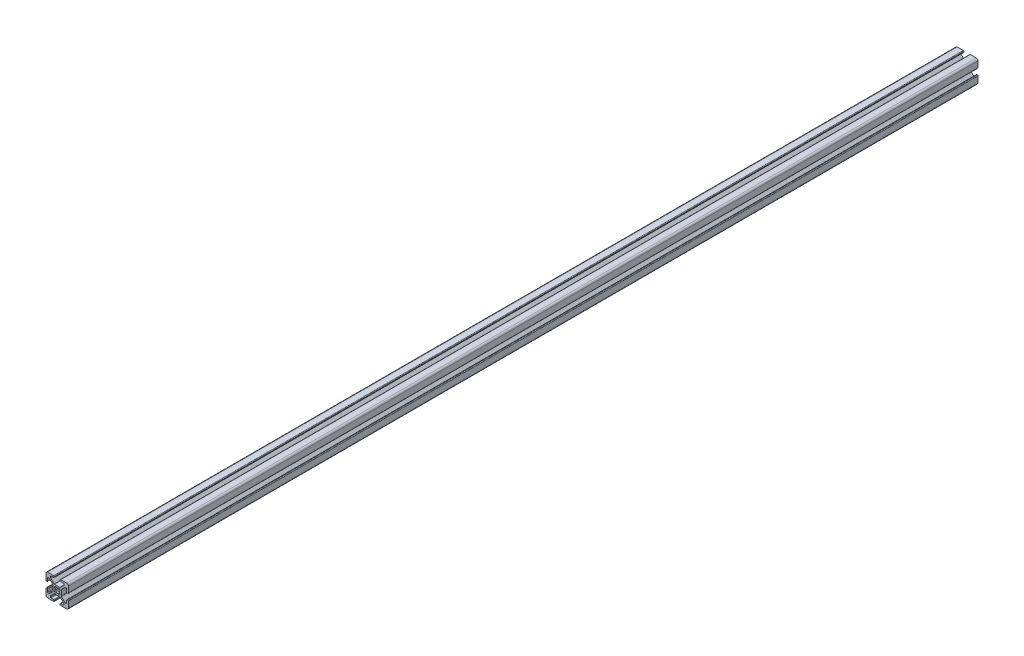
from build123d import *

# Parameters (mm, degrees)
EXTRUDE1_DEPTH = 406.4


with BuildPart() as part:
    # Sketch1 → Extrude1 (new body, symmetric)
    with BuildSketch(Plane.XY):
        with BuildLine():
            Line((9.492, 2.63), (9.008, 2.63))
            ThreePointArc((9.008, 2.63), (8.648789755, 2.778789755), (8.5, 3.138))
            Line((8.5, 3.138), (8.5, 5.487))
            ThreePointArc((8.5, 5.487), (8.351210245, 5.846210245), (7.992, 5.995))
            Line((7.992, 5.995), (7.266080661, 5.995))
            ThreePointArc((7.266080661, 5.995), (7.071677478, 5.956330803), (6.906870417, 5.846210245))
            Line((6.906870417, 5.846210245), (3.803789755, 2.743129583))
            ThreePointArc((3.803789755, 2.743129583), (3.693669197, 2.578322522), (3.655, 2.383919339))
            Line((3.655, 2.383919339), (3.655, -2.383919339))
            ThreePointArc((3.655, -2.383919339), (3.693669197, -2.578322522), (3.803789755, -2.743129583))
            Line((3.803789755, -2.743129583), (6.906870417, -5.846210245))
            ThreePointArc((6.906870417, -5.846210245), (7.071677478, -5.956330803), (7.266080661, -5.995))
            Line((7.266080661, -5.995), (7.992, -5.995))
            ThreePointArc((7.992, -5.995), (8.351210245, -5.846210245), (8.5, -5.487))
            Line((8.5, -5.487), (8.5, -3.138))
            ThreePointArc((8.5, -3.138), (8.648789755, -2.778789755), (9.008, -2.63))
            Line((9.008, -2.63), (9.492, -2.63))
            ThreePointArc((9.492, -2.63), (9.851210245, -2.778789755), (10, -3.138))
            Line((10, -3.138), (10, -8.5))
            ThreePointArc((10, -8.5), (9.560660172, -9.560660172), (8.5, -10))
            Line((8.5, -10), (3.138, -10))
            ThreePointArc((3.138, -10), (2.778789755, -9.851210245), (2.63, -9.492))
            Line((2.63, -9.492), (2.63, -9.008))
            ThreePointArc((2.63, -9.008), (2.778789755, -8.648789755), (3.138, -8.5))
            Line((3.138, -8.5), (5.487, -8.5))
            ThreePointArc((5.487, -8.5), (5.846210245, -8.351210245), (5.995, -7.992))
            Line((5.995, -7.992), (5.995, -7.266080661))
            ThreePointArc((5.995, -7.266080661), (5.956330803, -7.071677478), (5.846210245, -6.906870417))
            Line((5.846210245, -6.906870417), (2.743129583, -3.803789755))
            ThreePointArc((2.743129583, -3.803789755), (2.578322522, -3.693669197), (2.383919339, -3.655))
            Line((2.383919339, -3.655), (-2.383919339, -3.655))
            ThreePointArc((-2.383919339, -3.655), (-2.578322522, -3.693669197), (-2.743129583, -3.803789755))
            Line((-2.743129583, -3.803789755), (-5.846210245, -6.906870417))
            ThreePointArc((-5.846210245, -6.906870417), (-5.956330803, -7.071677478), (-5.995, -7.266080661))
            Line((-5.995, -7.266080661), (-5.995, -7.992))
            ThreePointArc((-5.995, -7.992), (-5.846210245, -8.351210245), (-5.487, -8.5))
            Line((-5.487, -8.5), (-3.138, -8.5))
            ThreePointArc((-3.138, -8.5), (-2.778789755, -8.648789755), (-2.63, -9.008))
            Line((-2.63, -9.008), (-2.63, -9.492))
            ThreePointArc((-2.63, -9.492), (-2.778789755, -9.851210245), (-3.138, -10))
            Line((-3.138, -10), (-8.5, -10))
            ThreePointArc((-8.5, -10), (-9.560660172, -9.560660172), (-10, -8.5))
            Line((-10, -8.5), (-10, -3.138))
            ThreePointArc((-10, -3.138), (-9.851210245, -2.778789755), (-9.492, -2.63))
            Line((-9.492, -2.63), (-9.008, -2.63))
            ThreePointArc((-9.008, -2.63), (-8.648789755, -2.778789755), (-8.5, -3.138))
            Line((-8.5, -3.138), (-8.5, -5.487))
            ThreePointArc((-8.5, -5.487), (-8.351210245, -5.846210245), (-7.992, -5.995))
            Line((-7.992, -5.995), (-7.266080661, -5.995))
            ThreePointArc((-7.266080661, -5.995), (-7.071677478, -5.956330803), (-6.906870417, -5.846210245))
            Line((-6.906870417, -5.846210245), (-3.803789755, -2.743129583))
            ThreePointArc((-3.803789755, -2.743129583), (-3.693669197, -2.578322522), (-3.655, -2.383919339))
            Line((-3.655, -2.383919339), (-3.655, 2.383919339))
            ThreePointArc((-3.655, 2.383919339), (-3.693669197, 2.578322522), (-3.803789755, 2.743129583))
            Line((-3.803789755, 2.743129583), (-6.906870417, 5.846210245))
            ThreePointArc((-6.906870417, 5.846210245), (-7.071677478, 5.956330803), (-7.266080661, 5.995))
            Line((-7.266080661, 5.995), (-7.992, 5.995))
            ThreePointArc((-7.992, 5.995), (-8.351210245, 5.846210245), (-8.5, 5.487))
            Line((-8.5, 5.487), (-8.5, 3.138))
            ThreePointArc((-8.5, 3.138), (-8.648789755, 2.778789755), (-9.008, 2.63))
            Line((-9.008, 2.63), (-9.492, 2.63))
            ThreePointArc((-9.492, 2.63), (-9.851210245, 2.778789755), (-10, 3.138))
            Line((-10, 3.138), (-10, 8.5))
            ThreePointArc((-10, 8.5), (-9.560660172, 9.560660172), (-8.5, 10))
            Line((-8.5, 10), (-3.138, 10))
            ThreePointArc((-3.138, 10), (-2.778789755, 9.851210245), (-2.63, 9.492))
            Line((-2.63, 9.492), (-2.63, 9.008))
            ThreePointArc((-2.63, 9.008), (-2.778789755, 8.648789755), (-3.138, 8.5))
            Line((-3.138, 8.5), (-5.487, 8.5))
            ThreePointArc((-5.487, 8.5), (-5.846210245, 8.351210245), (-5.995, 7.992))
            Line((-5.995, 7.992), (-5.995, 7.266080661))
            ThreePointArc((-5.995, 7.266080661), (-5.956330803, 7.071677478), (-5.846210245, 6.906870417))
            Line((-5.846210245, 6.906870417), (-2.743129583, 3.803789755))
            ThreePointArc((-2.743129583, 3.803789755), (-2.578322522, 3.693669197), (-2.383919339, 3.655))
            Line((-2.383919339, 3.655), (2.383919339, 3.655))
            ThreePointArc((2.383919339, 3.655), (2.578322522, 3.693669197), (2.743129583, 3.803789755))
            Line((2.743129583, 3.803789755), (5.846210245, 6.906870417))
            ThreePointArc((5.846210245, 6.906870417), (5.956330803, 7.071677478), (5.995, 7.266080661))
            Line((5.995, 7.266080661), (5.995, 7.992))
            ThreePointArc((5.995, 7.992), (5.846210245, 8.351210245), (5.487, 8.5))
            Line((5.487, 8.5), (3.138, 8.5))
            ThreePointArc((3.138, 8.5), (2.778789755, 8.648789755), (2.63, 9.008))
            Line((2.63, 9.008), (2.63, 9.492))
            ThreePointArc((2.63, 9.492), (2.778789755, 9.851210245), (3.138, 10))
            Line((3.138, 10), (8.5, 10))
            ThreePointArc((8.5, 10), (9.560660172, 9.560660172), (10, 8.5))
            Line((10, 8.5), (10, 3.138))
            ThreePointArc((10, 3.138), (9.851210245, 2.778789755), (9.492, 2.63))
        make_face()
        with BuildLine():
            Line((2.124900844, -2.304505966), (2.304505966, -2.124900844))
            ThreePointArc((2.304505966, -2.124900844), (2.505938017, -1.356467811), (1.935133506, -0.803976718))
            ThreePointArc((1.935133506, -0.803976718), (2.0955, 0), (1.935133506, 0.803976718))
            ThreePointArc((1.935133506, 0.803976718), (2.505938017, 1.356467811), (2.304505966, 2.124900844))
            Line((2.304505966, 2.124900844), (2.124900844, 2.304505966))
            ThreePointArc((2.124900844, 2.304505966), (1.356467811, 2.505938017), (0.803976718, 1.935133506))
            ThreePointArc((0.803976718, 1.935133506), (0, 2.0955), (-0.803976718, 1.935133506))
            ThreePointArc((-0.803976718, 1.935133506), (-1.356467811, 2.505938017), (-2.124900844, 2.304505966))
            Line((-2.124900844, 2.304505966), (-2.304505966, 2.124900844))
            ThreePointArc((-2.304505966, 2.124900844), (-2.505938017, 1.356467811), (-1.935133506, 0.803976718))
            ThreePointArc((-1.935133506, 0.803976718), (-2.0955, 0), (-1.935133506, -0.803976718))
            ThreePointArc((-1.935133506, -0.803976718), (-2.505938017, -1.356467811), (-2.304505966, -2.124900844))
            Line((-2.304505966, -2.124900844), (-2.124900844, -2.304505966))
            ThreePointArc((-2.124900844, -2.304505966), (-1.356467811, -2.505938017), (-0.803976718, -1.935133506))
            ThreePointArc((-0.803976718, -1.935133506), (0, -2.0955), (0.803976718, -1.935133506))
            ThreePointArc((0.803976718, -1.935133506), (1.356467811, -2.505938017), (2.124900844, -2.304505966))
        make_face(mode=Mode.SUBTRACT)
    extrude(amount=EXTRUDE1_DEPTH, both=True)


solid = part.part
